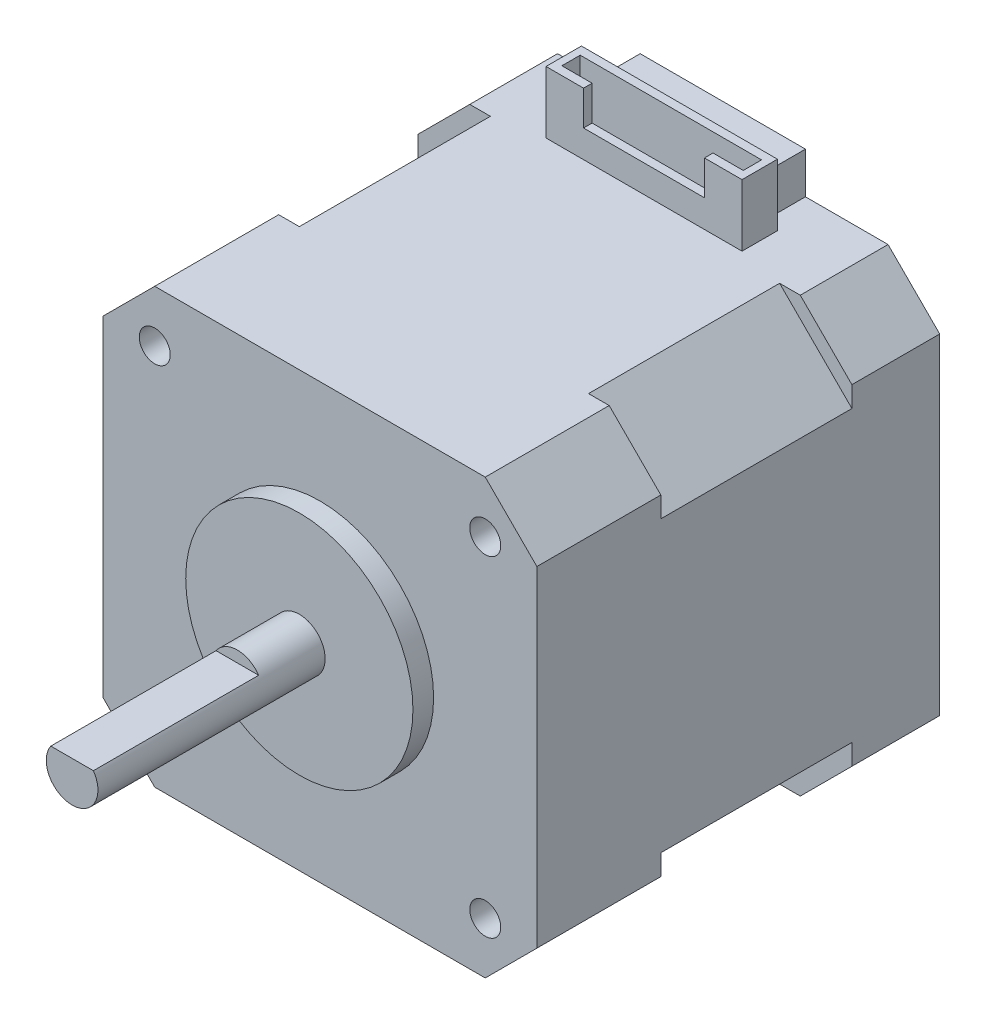
from build123d import *

# Parameters (mm, degrees)
EXTRUDE_1_DEPTH     = 39
CUT_EXTRUDE_1_DEPTH = 18.5
SKETCH_3_R          = 11
EXTRUDE_2_DEPTH     = 2
SKETCH_4_R          = 2.5
EXTRUDE_3_DEPTH     = 22
CUT_EXTRUDE_2_DEPTH = 16
SKETCH_6_R          = 1.5
CUT_EXTRUDE_3_DEPTH = 5
SKETCH_7_W          = 16
SKETCH_7_H          = 4.2
EXTRUDE_4_DEPTH     = 4
SKETCH_8_W          = 18.978516406
SKETCH_8_H          = 3.428953429
SKETCH_8_W_2        = 17.559561908
SKETCH_8_H_2        = 1.773693122
EXTRUDE_5_DEPTH     = 6
SKETCH_9_W          = 11.707219222
SKETCH_9_H          = 3.341648532
CUT_EXTRUDE_4_DEPTH = 2


with BuildPart() as part:
    # 草图1 → 凸台-拉伸1 (new body)
    with BuildSketch(Plane.XY):
        Polygon((0, 37), (5, 42), (37, 42), (42, 37), (42, 5), (37, 0), (5, 0), (0, 5), align=None)
    extrude(amount=EXTRUDE_1_DEPTH)

    # 草图2 → 切除-拉伸1 (cut)
    with BuildSketch(Plane.XY.offset(27)):
        Polygon((37, 42), (35, 42), (42, 35), (42, 37), align=None)
        Polygon((5, 42), (0, 37), (0, 35), (7, 42), align=None)
        Polygon((5, 0), (7, 0), (0, 7), (0, 5), align=None)
        Polygon((37, 0), (42, 5), (42, 7), (35, 0), align=None)
    extrude(amount=-CUT_EXTRUDE_1_DEPTH, mode=Mode.SUBTRACT)

    # 草图3 → 凸台-拉伸2 (add)
    with BuildSketch(Plane.XY.offset(39)):
        with Locations((21, 21)):
            Circle(SKETCH_3_R)
    extrude(amount=EXTRUDE_2_DEPTH)

    # 草图4 → 凸台-拉伸3 (add)
    with BuildSketch(Plane.XY.offset(41)):
        with Locations((21, 21)):
            Circle(SKETCH_4_R)
    extrude(amount=EXTRUDE_3_DEPTH)

    # 草图5 → 切除-拉伸2 (cut)
    with BuildSketch(Plane.XY.offset(63)):
        with BuildLine():
            Line((18.937577059, 22.412944307), (23.062422941, 22.412944307))
            ThreePointArc((23.062422941, 22.412944307), (21, 23.5), (18.937577059, 22.412944307))
        make_face()
    extrude(amount=-CUT_EXTRUDE_2_DEPTH, mode=Mode.SUBTRACT)

    # 草图6 → 切除-拉伸3 (cut)
    with BuildSketch(Plane.XY.offset(39)):
        with Locations((37, 5)):
            Circle(SKETCH_6_R)
        with Locations((5, 5)):
            Circle(SKETCH_6_R)
        with Locations((37, 37)):
            Circle(SKETCH_6_R)
        with Locations((5, 37)):
            Circle(SKETCH_6_R)
    extrude(amount=-CUT_EXTRUDE_3_DEPTH, mode=Mode.SUBTRACT)

    # 草图7 → 凸台-拉伸4 (add)
    with BuildSketch(Plane(origin=(0, 42, 0), x_dir=(1, 0, 0), z_dir=(0, 1, 0))):
        with Locations((21, -2.1)):
            Rectangle(SKETCH_7_W, SKETCH_7_H)
    extrude(amount=EXTRUDE_4_DEPTH)

    # 草图8 → 凸台-拉伸5 (add)
    with BuildSketch(Plane(origin=(0, 42, 0), x_dir=(1, 0, 0), z_dir=(0, 1, 0))):
        with Locations((21, -5.914476715)):
            Rectangle(SKETCH_8_W, SKETCH_8_H)
        with Locations((21, -5.914476714)):
            Rectangle(SKETCH_8_W_2, SKETCH_8_H_2, mode=Mode.SUBTRACT)
    extrude(amount=EXTRUDE_5_DEPTH)

    # 草图9 → 切除-拉伸4 (cut)
    with BuildSketch(Plane.XY.offset(7.628953429)):
        with Locations((21, 46.329175734)):
            Rectangle(SKETCH_9_W, SKETCH_9_H)
    extrude(amount=-CUT_EXTRUDE_4_DEPTH, mode=Mode.SUBTRACT)


solid = part.part
